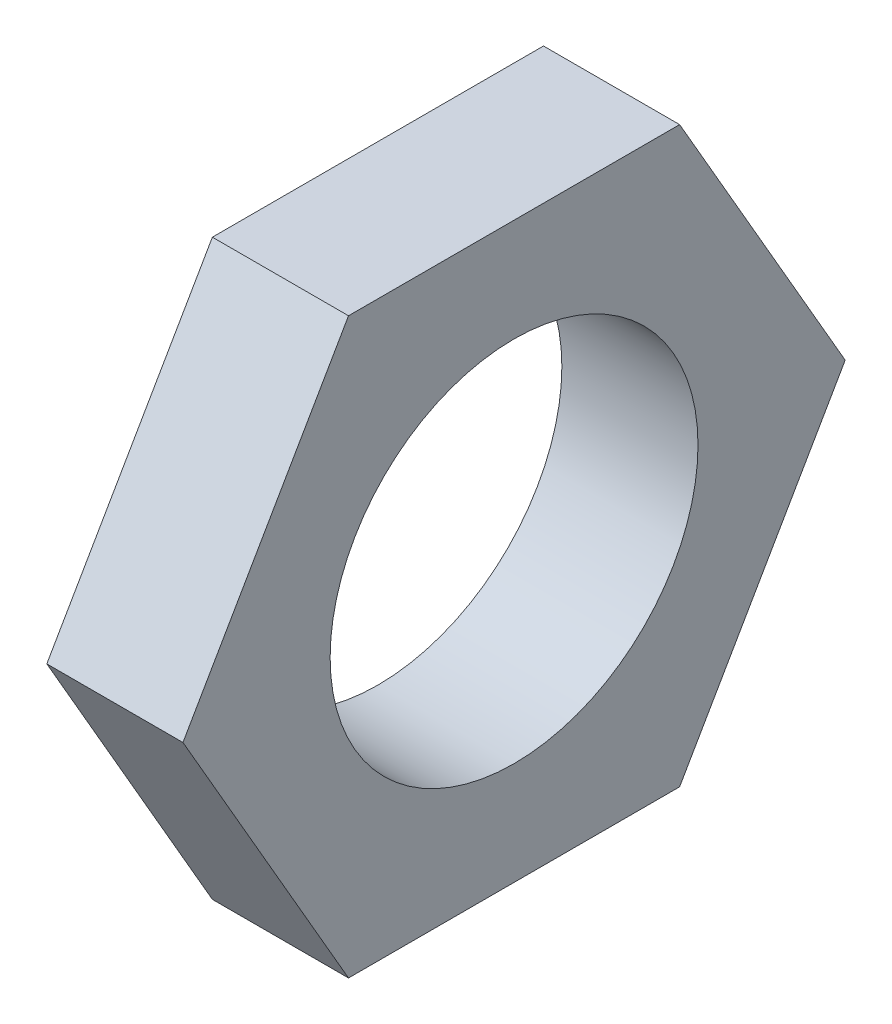
from build123d import *

# Parameters (mm, degrees)
SKETCH1_R           = 3.175
BOSS_EXTRUDE1_DEPTH = 2.35


with BuildPart() as part:
    # Sketch1 → Boss-Extrude1 (new body)
    with BuildSketch(Plane(origin=(0, 0, 0), x_dir=(0, 0, -1), z_dir=(1, 0, 0))):
        Polygon((5.715767665, 0), (2.857883832, 4.95), (-2.857883832, 4.95), (-5.715767665, 0), (-2.857883832, -4.95), (2.857883832, -4.95), align=None)
        Circle(SKETCH1_R, mode=Mode.SUBTRACT)
    extrude(amount=BOSS_EXTRUDE1_DEPTH)


solid = part.part
